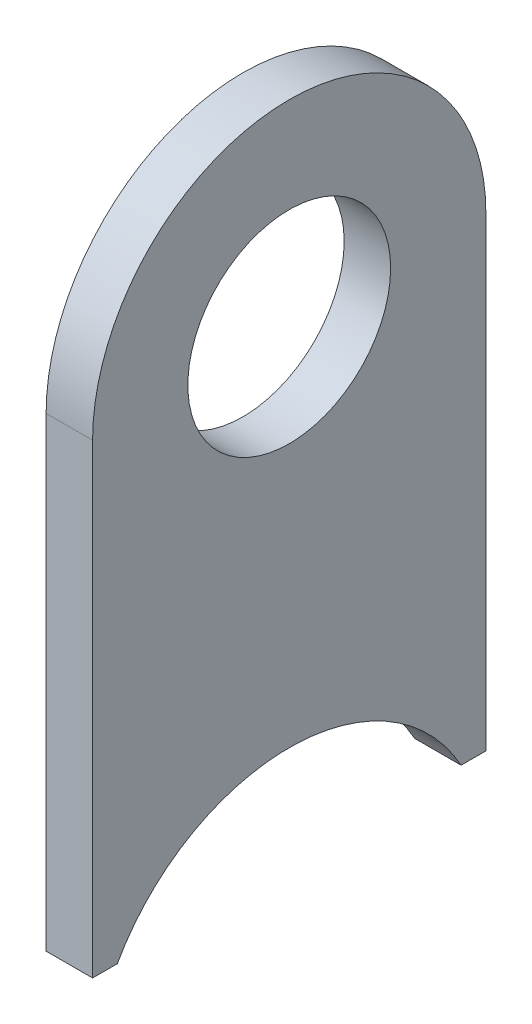
from build123d import *

# Parameters (mm, degrees)
BOSS_EXTRUDE1_DEPTH      = 1.5
BOSS_EXTRUDE1_DEPTH_BACK = 1.5
SKETCH1_R                = 6.54812


with BuildPart() as part:
    # Sketch1 → Boss-Extrude1 (new, two sides: drawn at the far end of the back side and taken through both)
    with BuildSketch(Plane(origin=(0, 0, 0), x_dir=(0, 0, -1), z_dir=(1, 0, 0)).offset(-BOSS_EXTRUDE1_DEPTH_BACK)):
        with BuildLine():
            Line((-12.7, 36.24812), (-12.7, 6.170899448))
            Line((-12.7, 6.170899448), (-11.1, 6.170899448))
            ThreePointArc((-11.1, 6.170899448), (0, 12.7), (11.1, 6.170899448))
            Line((11.1, 6.170899448), (12.7, 6.170899448))
            Line((12.7, 6.170899448), (12.7, 36.24812))
            ThreePointArc((12.7, 36.24812), (0, 48.94812), (-12.7, 36.24812))
        make_face()
        with Locations((0, 36.24812)):
            Circle(SKETCH1_R, mode=Mode.SUBTRACT)
    extrude(amount=BOSS_EXTRUDE1_DEPTH + BOSS_EXTRUDE1_DEPTH_BACK)


solid = part.part
